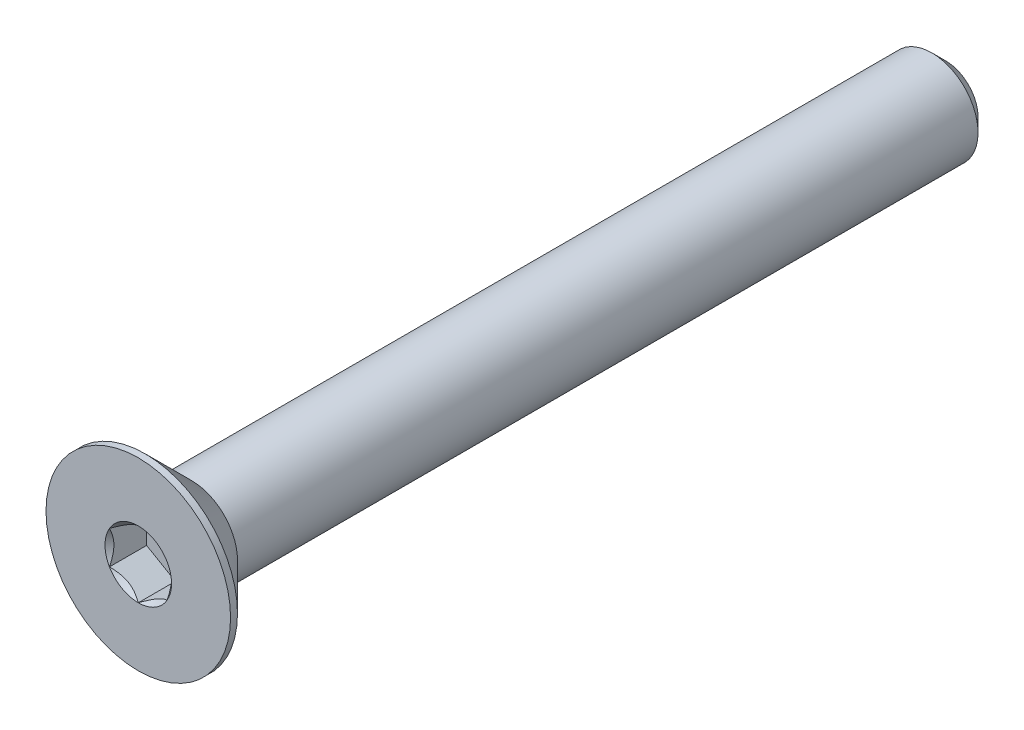
from build123d import *

# Parameters (mm, degrees)
SKETCH3_W          = 35
SKETCH3_H          = 2
CHAMFER1_SIZE      = 0.6
CUT_EXTRUDE1_DEPTH = 1.61
SKETCH9_R          = 1.443375673
CUT_EXTRUDE2_DEPTH = 1.61
CUT_EXTRUDE2_DRAFT = -45


with BuildPart() as part:
    # Sketch3 → Revolve1 (revolve)
    with BuildSketch(Plane(origin=(0, 0, 0), x_dir=(0, 0, -1), z_dir=(1, 0, 0))):
        with Locations((0, 1)):
            Rectangle(SKETCH3_W, SKETCH3_H)
    revolve(axis=Axis((0, 0, -17.5), (0, 0, 1)))

    # Chamfer1
    chamfer1_edges = [part.edges().sort_by_distance(p)[0] for p in [
        (0, -2, -17.5),
    ]]
    chamfer(chamfer1_edges, length=CHAMFER1_SIZE)

    # Sketch6 → Revolve2 (revolve)
    with BuildSketch(Plane(origin=(0, 0, 0), x_dir=(0, 0, -1), z_dir=(1, 0, 0))):
        Polygon((-17.5, 4), (-17.2, 4), (-15.2, 2), (-15.2, 0), (-17.5, 0), align=None)
    revolve(axis=Axis((0, 0, -17.5), (0, 0, 1)))

    # Sketch8 → Cut-Extrude1 (cut)
    with BuildSketch(Plane.XY.offset(17.5)):
        Polygon((0, 1.443375673), (-1.25, 0.721687836), (-1.25, -0.721687836), (0, -1.443375673), (1.25, -0.721687836), (1.25, 0.721687836), align=None)
    extrude(amount=-CUT_EXTRUDE1_DEPTH, mode=Mode.SUBTRACT)


with BuildPart() as cut_extrude2_tool:
    # Sketch9 → Cut-Extrude2 (with draft: the straight prism first)
    with BuildSketch(Plane.XY.offset(17.5)):
        Circle(SKETCH9_R)
    extrude(amount=-CUT_EXTRUDE2_DEPTH)
    # Cut-Extrude2: the draft: its side faces are tilted about the plane it starts from
    cut_extrude2_sides = [cut_extrude2_tool.faces().sort_by_distance(p)[0] for p in [
        (-1.443375673, 0, 16.695),
    ]]
    draft(cut_extrude2_sides, Plane.XY.offset(17.5), CUT_EXTRUDE2_DRAFT)


with BuildPart() as part_1:
    add(part.part)

    # Cut-Extrude2: cut by cut_extrude2_tool
    add(cut_extrude2_tool.part, mode=Mode.SUBTRACT)


solid = part_1.part
